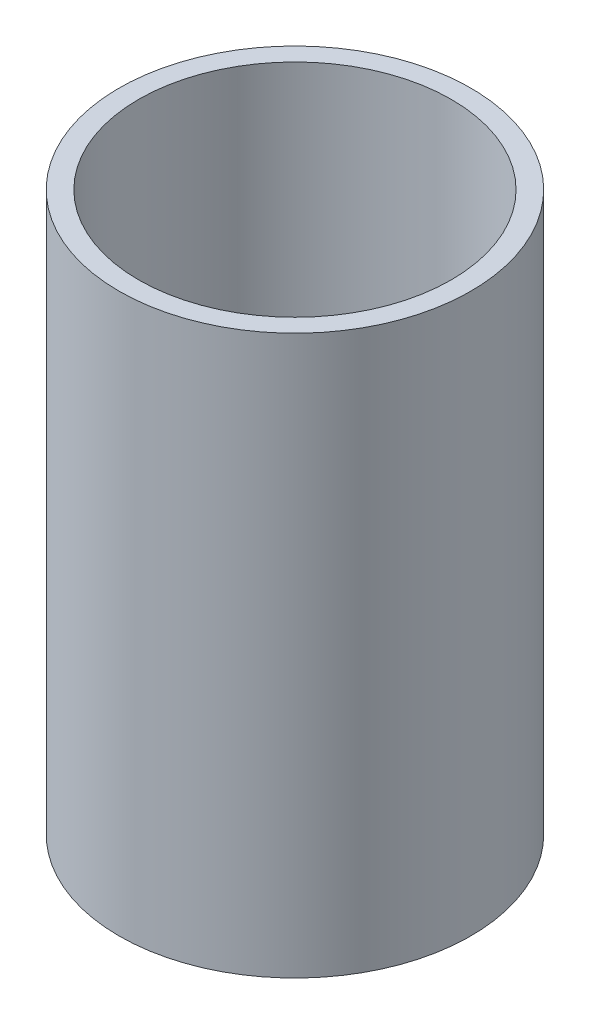
from build123d import *

# Parameters (mm, degrees)
ESQUISSE1_R        = 31.5
ESQUISSE1_R_2      = 28
BOSS_EXTRU_1_DEPTH = 100


with BuildPart() as part:
    # Esquisse1 → Boss.-Extru.1 (new body)
    with BuildSketch(Plane(origin=(0, 0, 0), x_dir=(1, 0, 0), z_dir=(0, 1, 0))):
        Circle(ESQUISSE1_R)
        Circle(ESQUISSE1_R_2, mode=Mode.SUBTRACT)
    extrude(amount=BOSS_EXTRU_1_DEPTH)


solid = part.part
